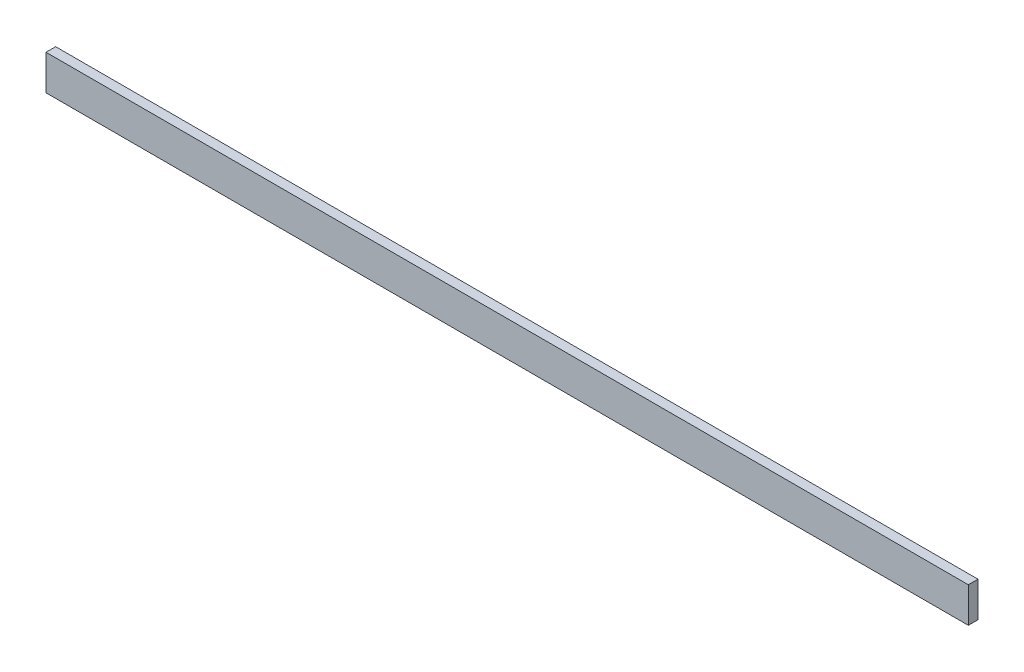
from build123d import *

# Parameters (mm, degrees)
ESQUISSE1_W      = 2100
ESQUISSE1_H      = 22
EXTRUSION1_DEPTH = 80


with BuildPart() as part:
    # Esquisse1 → Extrusion1 (new body)
    with BuildSketch(Plane(origin=(0, 0, 0), x_dir=(1, 0, 0), z_dir=(0, 1, 0))):
        with Locations((1050, 11)):
            Rectangle(ESQUISSE1_W, ESQUISSE1_H)
    extrude(amount=EXTRUSION1_DEPTH)


solid = part.part
